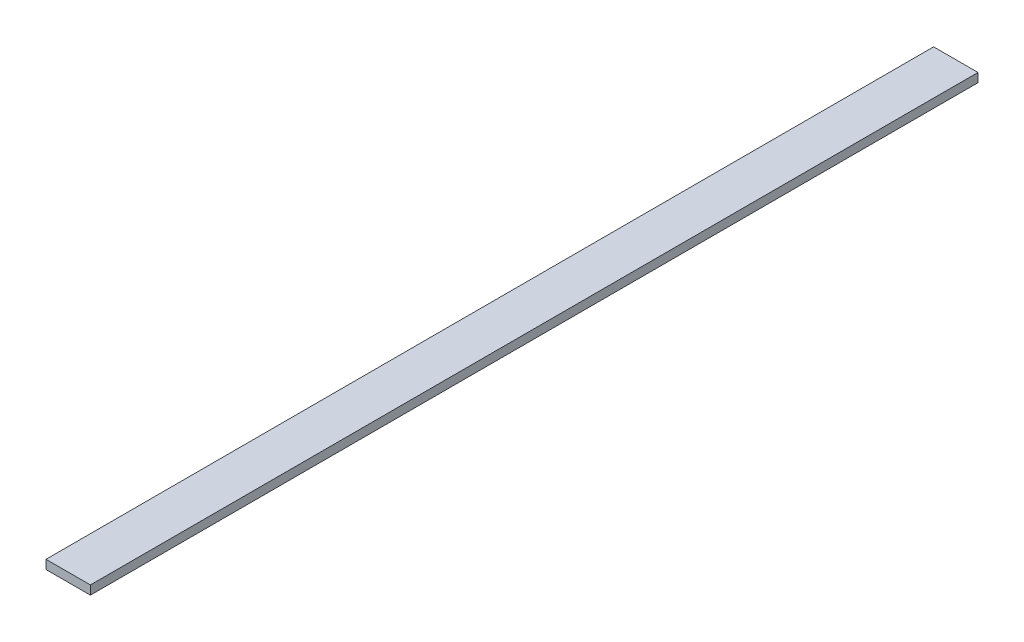
from build123d import *

# Parameters (mm, degrees)
SKETCH_1_W      = 100
SKETCH_1_H      = 20
EXTRUDE_1_DEPTH = 2000


with BuildPart() as part:
    # 草图1 → 凸台-拉伸1 (new body)
    with BuildSketch(Plane.XY):
        Rectangle(SKETCH_1_W, SKETCH_1_H)
    extrude(amount=EXTRUDE_1_DEPTH)


solid = part.part
